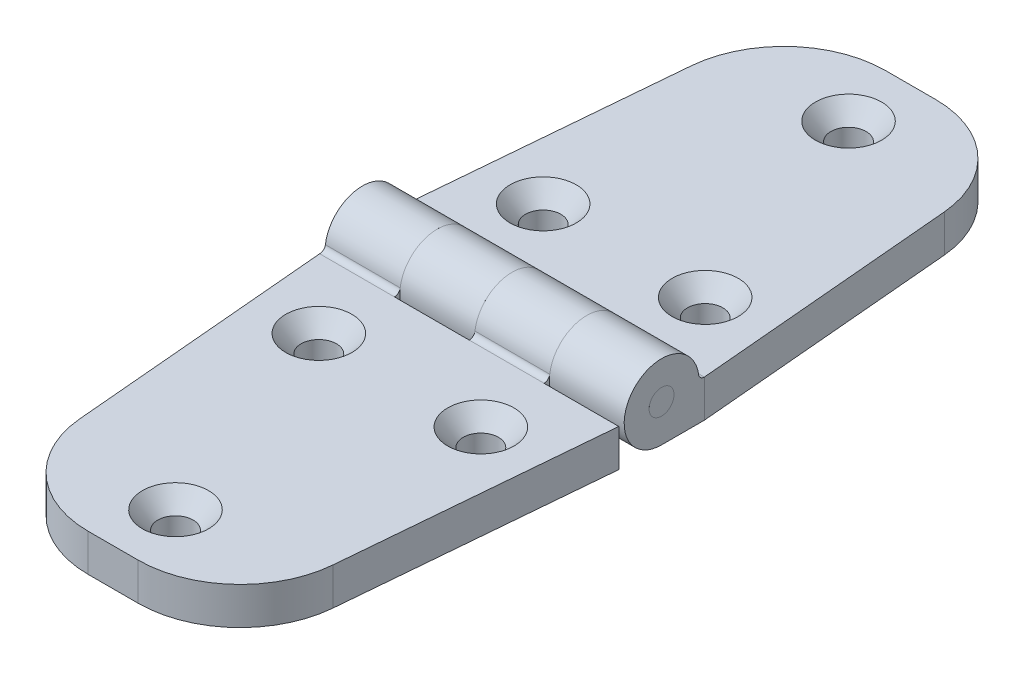
from build123d import *

# Parameters (mm, degrees)
SKETCH2_R                                     = 1.5875
EXTRUDE1_DEPTH                                = 19.05
SKETCH24_W                                    = 9.525
SKETCH24_H                                    = 10.208627108
CUT_EXTRUDE5_DEPTH                            = 10.525
SKETCH4_R                                     = 1.5875
EXTRUDE2_DEPTH                                = 19.05
EXTRUDE2_DEPTH_BACK                           = 19.05
SKETCH25_W                                    = 9.525
SKETCH25_H                                    = 10.166103935
CUT_EXTRUDE6_DEPTH                            = 10.525
SKETCH7_W                                     = 38.1
SKETCH7_H                                     = 1.5875
CUT_EXTRUDE4_DEPTH                            = 1056.132
CSK_FOR_8_FLAT_HEAD_MACHINE_SCREW1_AT_2_COUNT = 2
CSK_FOR_8_FLAT_HEAD_MACHINE_SCREW1_AT_2_PITCH = 30.381033994
CSK_FOR_8_FLAT_HEAD_MACHINE_SCREW1_AT_3_COUNT = 2
CSK_FOR_8_FLAT_HEAD_MACHINE_SCREW1_AT_3_PITCH = 30.381033994
CSK_FOR_8_FLAT_HEAD_MACHINE_SCREW1_AT_4_COUNT = 2
CSK_FOR_8_FLAT_HEAD_MACHINE_SCREW1_AT_4_PITCH = 58.074082873
CSK_FOR_8_FLAT_HEAD_MACHINE_SCREW1_AT_5_COUNT = 2
CSK_FOR_8_FLAT_HEAD_MACHINE_SCREW1_AT_5_PITCH = 58.074082873
CSK_FOR_8_FLAT_HEAD_MACHINE_SCREW1_AT_6_COUNT = 2
CSK_FOR_8_FLAT_HEAD_MACHINE_SCREW1_AT_6_PITCH = 85.725


with BuildPart() as part:
    # Sketch2 → Extrude1 (new body, symmetric)
    with BuildSketch(Plane(origin=(0, 0, 0), x_dir=(0, 0, -1), z_dir=(1, 0, 0))):
        with BuildLine():
            Line((0, 0), (-50.8, 0))
            Line((-50.8, 0), (-50.8, 4.7625))
            Line((-50.8, 4.7625), (-5.446127108, 4.7625))
            ThreePointArc((-5.446127108, 4.7625), (-4.963809985, 4.943641576), (-4.719976827, 5.3975))
            ThreePointArc((-4.719976827, 5.3975), (3.585079759, 7.897561303), (0, 0))
        make_face()
        with Locations((0, 4.7625)):
            Circle(SKETCH2_R, mode=Mode.SUBTRACT)
    extrude(amount=EXTRUDE1_DEPTH, both=True)

    # Sketch24 → Cut-Extrude5 (cut, through all)
    with BuildSketch(Plane(origin=(0, 0, 0), x_dir=(1, 0, 0), z_dir=(0, 1, 0))):
        with Locations((-4.7625, -0.341813554)):
            Rectangle(SKETCH24_W, SKETCH24_H)
        with Locations((14.2875, -0.341813554)):
            Rectangle(SKETCH24_W, SKETCH24_H)
    extrude(amount=CUT_EXTRUDE5_DEPTH, mode=Mode.SUBTRACT)


with BuildPart() as body_2:
    # Sketch4 → Extrude2 (new body, two sides)
    with BuildSketch(Plane(origin=(0, 0, 0), x_dir=(0, 0, -1), z_dir=(1, 0, 0))) as extrude2_sk:
        with BuildLine():
            Line((0, 0), (50.8, 0))
            Line((50.8, 0), (50.8, 4.7625))
            Line((50.8, 4.7625), (5.446127108, 4.7625))
            ThreePointArc((5.446127108, 4.7625), (4.963809985, 4.943641576), (4.719976827, 5.3975))
            ThreePointArc((4.719976827, 5.3975), (-3.585079759, 7.897561303), (0, 0))
        make_face()
        with Locations((0, 4.7625)):
            Circle(SKETCH4_R, mode=Mode.SUBTRACT)
    extrude(amount=EXTRUDE2_DEPTH)
    extrude(extrude2_sk.sketch, amount=-EXTRUDE2_DEPTH_BACK)

    # Sketch25 → Cut-Extrude6 (cut, through all)
    with BuildSketch(Plane(origin=(0, 0, 0), x_dir=(1, 0, 0), z_dir=(0, 1, 0))):
        with Locations((-14.2875, 0.363075141)):
            Rectangle(SKETCH25_W, SKETCH25_H)
        with Locations((4.7625, 0.363075141)):
            Rectangle(SKETCH25_W, SKETCH25_H)
    extrude(amount=CUT_EXTRUDE6_DEPTH, mode=Mode.SUBTRACT)


with BuildPart() as body_3:
    # Sketch7 → Revolve1 (revolve)
    with BuildSketch(Plane(origin=(0, 4.7625, 0), x_dir=(-1, 0, 0), z_dir=(0, 1, 0))):
        with Locations((0, -0.79375)):
            Rectangle(SKETCH7_W, SKETCH7_H)
    revolve(axis=Axis((19.05, 4.7625, 0), (-1, 0, 0)))


with BuildPart() as cut_extrude4_tool:
    # Sketch8 → Cut-Extrude4 (new body)
    with BuildSketch(Plane(origin=(0, 4.7625, 0), x_dir=(-1, 0, 0), z_dir=(0, 1, 0))):
        with BuildLine():
            Line((-19.05, -5.446127108), (-16.119818086, -38.938259646))
            ThreePointArc((-16.119818086, -38.938259646), (-11.953798316, -47.386112044), (-3.175, -50.8))
            Line((-3.175, -50.8), (3.175, -50.8))
            ThreePointArc((3.175, -50.8), (11.953798316, -47.386112044), (16.119818086, -38.938259646))
            Line((16.119818086, -38.938259646), (19.05, -5.446127108))
            Line((19.05, -5.446127108), (22.119129983, -5.446127108))
            Line((22.119129983, -5.446127108), (22.119129983, -53.464086311))
            Line((22.119129983, -53.464086311), (-22.119129983, -53.464086311))
            Line((-22.119129983, -53.464086311), (-22.119129983, -5.446127108))
            Line((-22.119129983, -5.446127108), (-19.05, -5.446127108))
        make_face()
        with BuildLine():
            Line((3.175, 50.8), (-3.175, 50.8))
            ThreePointArc((-3.175, 50.8), (-11.953798316, 47.386112044), (-16.119818086, 38.938259646))
            Line((-16.119818086, 38.938259646), (-19.05, 5.446127108))
            Line((-19.05, 5.446127108), (-22.119129983, 5.446127108))
            Line((-22.119129983, 5.446127108), (-22.119129983, 53.464086311))
            Line((-22.119129983, 53.464086311), (22.119129983, 53.464086311))
            Line((22.119129983, 53.464086311), (22.119129983, 5.446127108))
            Line((22.119129983, 5.446127108), (19.05, 5.446127108))
            Line((19.05, 5.446127108), (16.119818086, 38.938259646))
            ThreePointArc((16.119818086, 38.938259646), (11.953798316, 47.386112044), (3.175, 50.8))
        make_face()
    extrude(amount=-CUT_EXTRUDE4_DEPTH)


with BuildPart() as part_1:
    add(part.part)

    # Cut-Extrude4: cut by cut_extrude4_tool
    add(cut_extrude4_tool.part, mode=Mode.SUBTRACT)


with BuildPart() as body_2_1:
    add(body_2.part)

    # Cut-Extrude4: cut by cut_extrude4_tool
    add(cut_extrude4_tool.part, mode=Mode.SUBTRACT)

    # Sketch13 → CSK for #8 Flat Head Machine Screw1 (revolve, cut)
    with BuildSketch(Plane(origin=(0, 4.7625, -42.8625), x_dir=(0, 0, 1), z_dir=(1, 0, 0))):
        Polygon((0, 0), (0, 4.7625), (2.2479, 4.7625), (2.2479, 2.26450021), (4.2164, 0), align=None)
    csk_for_8_flat_head_machine_screw1 = revolve(axis=Axis((0, 11.1125, -42.8625), (0, -1, 0)), mode=Mode.SUBTRACT)

    # CSK for #8 Flat Head Machine Screw1 at 2: CSK for #8 Flat Head Machine Screw1 ×2
    with Locations(*[Vector(-0.339644464, 0, 0.9405539) * (i * CSK_FOR_8_FLAT_HEAD_MACHINE_SCREW1_AT_2_PITCH) for i in range(1, CSK_FOR_8_FLAT_HEAD_MACHINE_SCREW1_AT_2_COUNT)]):
        add(csk_for_8_flat_head_machine_screw1, mode=Mode.SUBTRACT)

    # CSK for #8 Flat Head Machine Screw1 at 3: CSK for #8 Flat Head Machine Screw1 ×2
    with Locations(*[Vector(0.339644464, 0, 0.9405539) * (i * CSK_FOR_8_FLAT_HEAD_MACHINE_SCREW1_AT_3_PITCH) for i in range(1, CSK_FOR_8_FLAT_HEAD_MACHINE_SCREW1_AT_3_COUNT)]):
        add(csk_for_8_flat_head_machine_screw1, mode=Mode.SUBTRACT)


with BuildPart() as part_2:
    add(part_1.part)

    # CSK for #8 Flat Head Machine Screw1 at 4: CSK for #8 Flat Head Machine Screw1 ×2
    with Locations(*[Vector(-0.17768253, 0, 0.984087861) * (i * CSK_FOR_8_FLAT_HEAD_MACHINE_SCREW1_AT_4_PITCH) for i in range(1, CSK_FOR_8_FLAT_HEAD_MACHINE_SCREW1_AT_4_COUNT)]):
        add(csk_for_8_flat_head_machine_screw1, mode=Mode.SUBTRACT)

    # CSK for #8 Flat Head Machine Screw1 at 5: CSK for #8 Flat Head Machine Screw1 ×2
    with Locations(*[Vector(0.17768253, 0, 0.984087861) * (i * CSK_FOR_8_FLAT_HEAD_MACHINE_SCREW1_AT_5_PITCH) for i in range(1, CSK_FOR_8_FLAT_HEAD_MACHINE_SCREW1_AT_5_COUNT)]):
        add(csk_for_8_flat_head_machine_screw1, mode=Mode.SUBTRACT)

    # CSK for #8 Flat Head Machine Screw1 at 6: CSK for #8 Flat Head Machine Screw1 ×2
    with Locations(*[(0, 0, i * CSK_FOR_8_FLAT_HEAD_MACHINE_SCREW1_AT_6_PITCH) for i in range(1, CSK_FOR_8_FLAT_HEAD_MACHINE_SCREW1_AT_6_COUNT)]):
        add(csk_for_8_flat_head_machine_screw1, mode=Mode.SUBTRACT)


solid = Compound([body_3.part, body_2_1.part, part_2.part])
